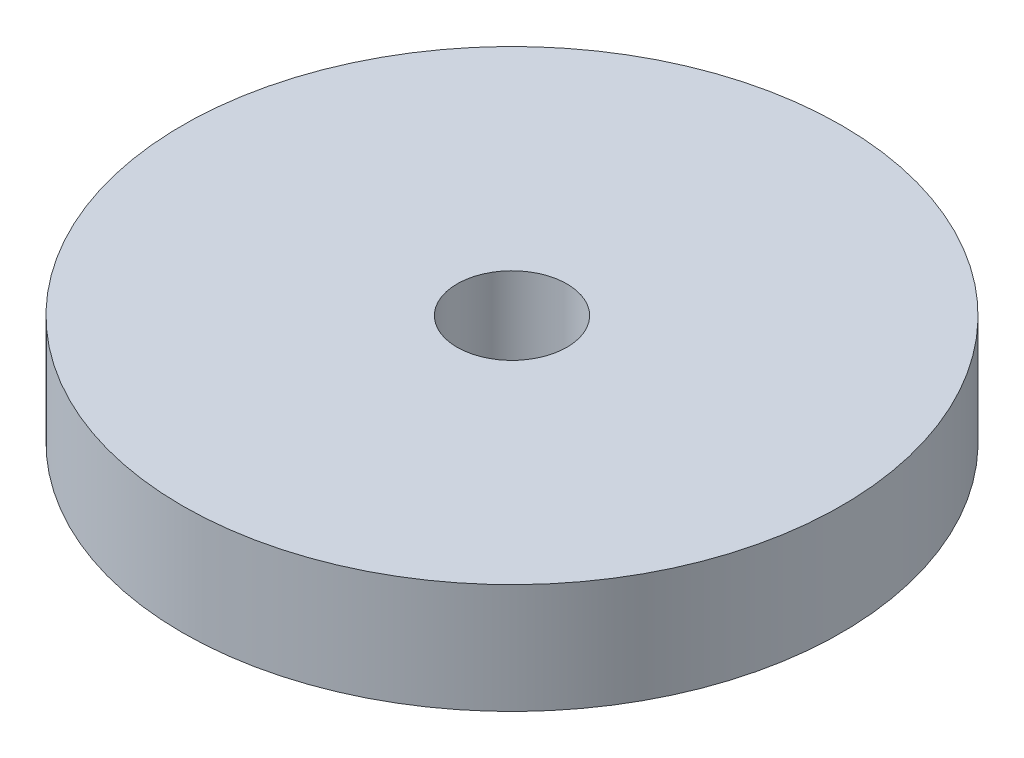
from build123d import *

# Parameters (mm, degrees)
SKETCH1_R           = 9.525
SKETCH1_R_2         = 1.5875
BOSS_EXTRUDE1_DEPTH = 3.175


with BuildPart() as part:
    # Sketch1 → Boss-Extrude1 (new body)
    with BuildSketch(Plane(origin=(0, 0, 0), x_dir=(1, 0, 0), z_dir=(0, 1, 0))):
        Circle(SKETCH1_R)
        Circle(SKETCH1_R_2, mode=Mode.SUBTRACT)
    extrude(amount=BOSS_EXTRUDE1_DEPTH)


solid = part.part
